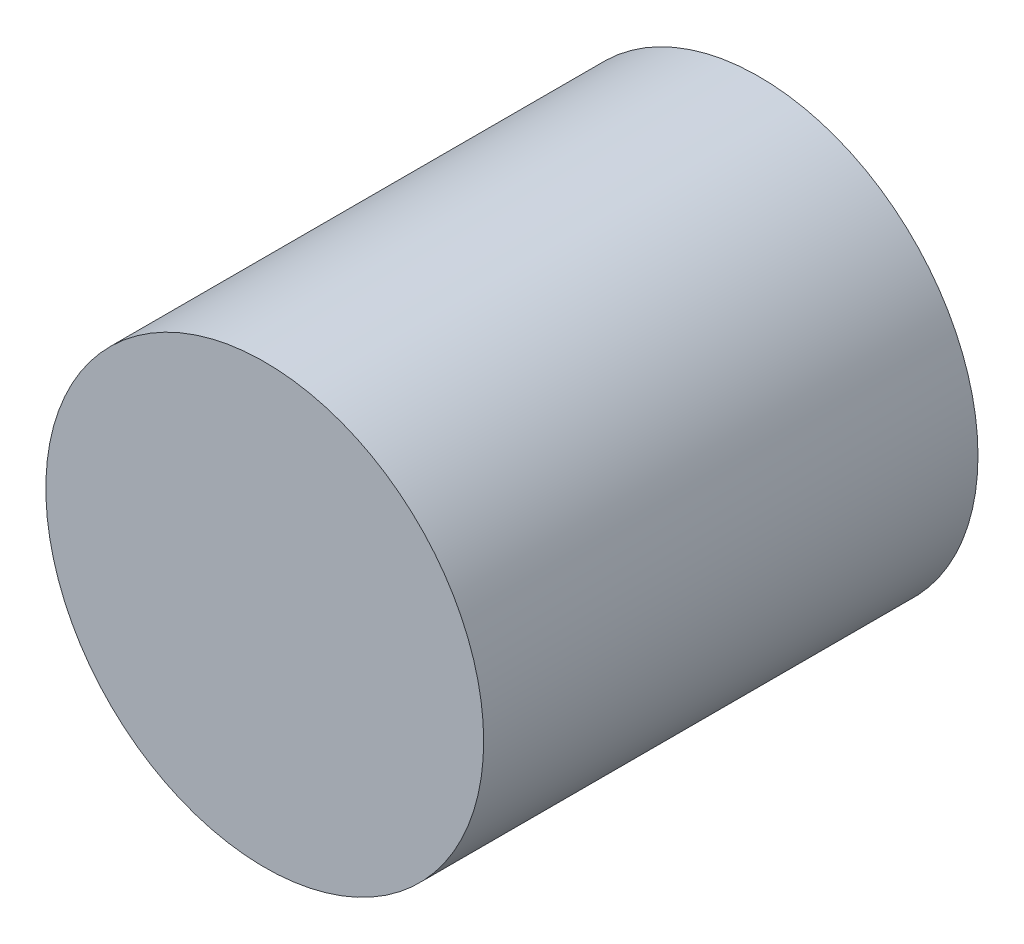
from build123d import *

# Parameters (mm, degrees)
SKETCH1_R           = 1.55
BOSS_EXTRUDE1_DEPTH = 3.5


with BuildPart() as part:
    # Sketch1 → Boss-Extrude1 (new body)
    with BuildSketch(Plane.XY):
        Circle(SKETCH1_R)
    extrude(amount=BOSS_EXTRUDE1_DEPTH)


solid = part.part
